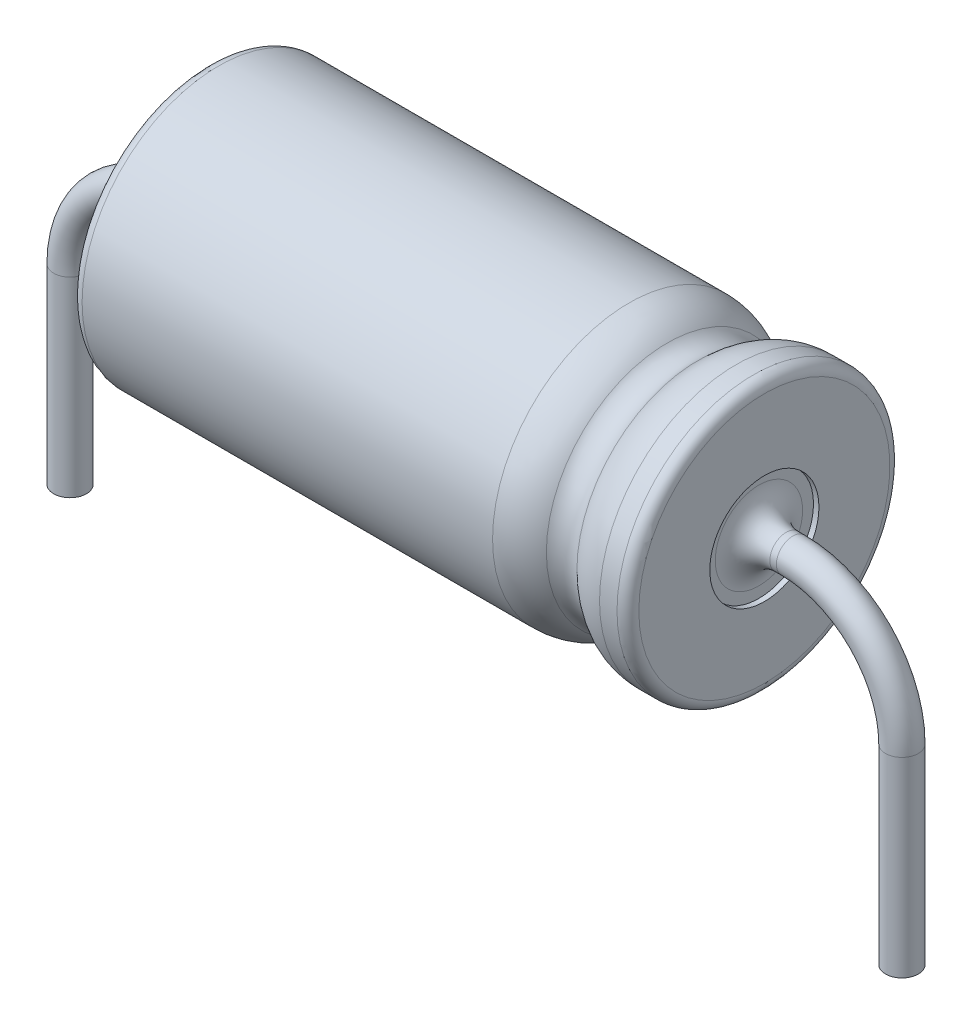
from build123d import *

# Parameters (mm, degrees)
SKETCH2_R                = 1
CUT_EXTRUDE1_DEPTH       = 0.1
SKETCH3_R                = 1
CUT_EXTRUDE2_DEPTH       = 0.1
FILLET1_R                = 0.2
SKETCH4_R                = 0.3
BOSS_EXTRUDE1_DEPTH      = 0.62
BOSS_EXTRUDE1_DEPTH_BACK = 10.62
FILLET2_R                = 0.5
SKETCH7_R                = 0.3


with BuildPart() as part:
    # Sketch1 → Base-Revolve-Thin (revolve)
    with BuildSketch(Plane.XY):
        Polygon((-12.72, 2.5), (-12.72, 5), (-2.52, 5), (-2.52, 2.5), (-3.52, 2.5), (-3.52, 4), (-11.72, 4), (-11.72, 2.5), align=None)
    revolve(axis=Axis((-2.52, 2.5, 0), (-1, 0, 0)))

    # Sketch2 → Cut-Extrude1 (cut)
    with BuildSketch(Plane(origin=(-2.52, 0, 0), x_dir=(0, 0, -1), z_dir=(1, 0, 0))):
        with Locations((0, 2.5)):
            Circle(SKETCH2_R)
    extrude(amount=-CUT_EXTRUDE1_DEPTH, mode=Mode.SUBTRACT)

    # Sketch3 → Cut-Extrude2 (cut)
    with BuildSketch(Plane.ZY.offset(12.72)):
        with Locations((0, 2.5)):
            Circle(SKETCH3_R)
    extrude(amount=-CUT_EXTRUDE2_DEPTH, mode=Mode.SUBTRACT)

    # Fillet1
    fillet1_edges = [part.edges().sort_by_distance(p)[0] for p in [
        (-2.52, 0, 0),
        (-12.72, 0, 0),
    ]]
    fillet(fillet1_edges, radius=FILLET1_R)

    # Sketch4 → Boss-Extrude1 (add, two sides)
    with BuildSketch(Plane(origin=(-2.62, 0, 0), x_dir=(0, 0, -1), z_dir=(1, 0, 0))) as boss_extrude1_sk:
        with Locations((0, 2.5)):
            Circle(SKETCH4_R)
    extrude(amount=BOSS_EXTRUDE1_DEPTH)
    extrude(boss_extrude1_sk.sketch, amount=-BOSS_EXTRUDE1_DEPTH_BACK)

    # Fillet2
    fillet2_edges = [part.edges().sort_by_distance(p)[0] for p in [
        (-2.62, 2.5, 0.3),
        (-12.62, 2.5, 0.3),
    ]]
    fillet(fillet2_edges, radius=FILLET2_R)

    # Boss-Sweep2: sweep along a path in Sketch5
    with BuildLine(Plane.XY) as boss_sweep2_path:
        Line((0, -3), (0, 0.5))
        ThreePointArc((0, 0.5), (-0.585786438, 1.914213562), (-2, 2.5))
    # Sketch7 → Boss-Sweep2 (sweep)
    with BuildSketch(Plane(origin=(-2, 0, 0), x_dir=(0, 0, -1), z_dir=(1, 0, 0))):
        with Locations((0, 2.5)):
            Circle(SKETCH7_R)
    boss_sweep2 = sweep(path=boss_sweep2_path.line)

    # Mirror1: Boss-Sweep2 across plane
    add(boss_sweep2.mirror(Plane(origin=(-7.62, 0, 0), x_dir=(0, 0, 1), z_dir=(1, 0, 0))))

    # Sketch8 → Cut-Revolve1 (revolve, cut)
    with BuildSketch(Plane.XY):
        with BuildLine():
            Line((-3.040246079, 5), (-4.999837057, 5))
            ThreePointArc((-4.999837057, 5), (-4.621872773, 4.925820177), (-4.299983136, 4.714286))
            ThreePointArc((-4.299983136, 4.714286), (-4.020041568, 4.6000004), (-3.7401, 4.714286))
            ThreePointArc((-3.7401, 4.714286), (-3.418210363, 4.925820177), (-3.040246079, 5))
        make_face()
    revolve(axis=Axis((-2.979129248, 2.5, 0), (-1, 0, 0)), mode=Mode.SUBTRACT)


solid = part.part
